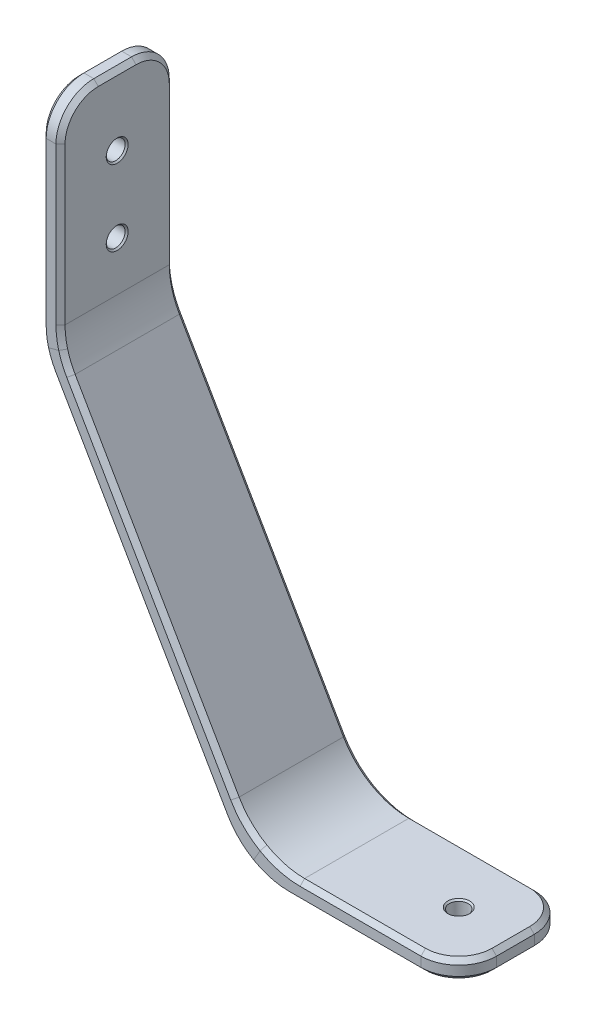
from build123d import *

# Parameters (mm, degrees)
SKETCH2_W                    = 3.175
SKETCH2_H                    = 19.05
F_1_8_0_125_DIAMETER_HOLE1_D = 3.175
F_1_8_0_125_DIAMETER_HOLE2_D = 3.175
FILLET1_R                    = 12.7
FILLET2_R                    = 6.35
CHAMFER3_SIZE                = 0.762
CHAMFER2_SIZE                = 0.254


with BuildPart() as part:
    # Sweep1: sweep along a path in Sketch1
    with BuildLine(Plane.XY) as sweep1_path:
        Line((0, 0), (0, -36.5125))
        Line((0, -36.5125), (33.61082832, -94.728162334))
        Line((33.61082832, -94.728162334), (68.53582832, -94.728162334))
    # Sketch2 → Sweep1 (sweep)
    with BuildSketch(Plane(origin=(0, 0, 0), x_dir=(1, 0, 0), z_dir=(0, 1, 0))):
        Rectangle(SKETCH2_W, SKETCH2_H)
    sweep(path=sweep1_path.line, transition=Transition.RIGHT)

    # 1/8 (0.125) Diameter Hole1 (through all)
    with Locations(Plane(origin=(1.5875, 0, 0), x_dir=(0, 0, -1), z_dir=(1, 0, 0))):
        with Locations((0, -11.693565329), (0, -24.393565329)):
            Hole(F_1_8_0_125_DIAMETER_HOLE1_D / 2)

    # 1/8 (0.125) Diameter Hole2 (through all)
    with Locations(Plane(origin=(0, -93.140662334, 0), x_dir=(1, 0, 0), z_dir=(0, 1, 0))):
        with Locations((59.01082832, 0)):
            Hole(F_1_8_0_125_DIAMETER_HOLE2_D / 2)

    # Fillet1
    fillet1_edges = [part.edges().sort_by_distance(p)[0] for p in [
        (1.5875, -36.087130657, 0),
        (-1.5875, -36.937869343, 0),
        (32.694284767, -96.315662334, 0),
        (34.527371872, -93.140662334, 0),
    ]]
    fillet(fillet1_edges, radius=FILLET1_R)

    # Fillet2
    fillet2_edges = [part.edges().sort_by_distance(p)[0] for p in [
        (0, 0, -9.525),
        (0, 0, 9.525),
        (68.53582832, -94.728162334, -9.525),
        (68.53582832, -94.728162334, 9.525),
    ]]
    fillet(fillet2_edges, radius=FILLET2_R)

    # Chamfer3
    chamfer3_edges = [part.edges().sort_by_distance(p)[0] for p in [
        (68.53582832, -96.315662334, 0),
        (66.67595638, -96.315662334, 7.665128061),
        (66.67595638, -96.315662334, -7.665128061),
        (68.53582832, -93.140662334, 0),
        (66.67595638, -93.140662334, 7.665128061),
        (66.67595638, -93.140662334, -7.665128061),
        (1.5875, 0, 0),
        (-1.5875, 0, 0),
        (-1.5875, -19.9424573, -9.525),
        (-1.5875, -19.9424573, 9.525),
        (-1.5875, -1.859871939, 7.665128061),
        (-1.5875, -1.859871939, -7.665128061),
        (1.5875, -19.517087957, -9.525),
        (1.5875, -19.517087957, 9.525),
        (1.5875, -1.859871939, 7.665128061),
        (1.5875, -1.859871939, -7.665128061),
        (51.106230753, -96.315662334, -9.525),
        (51.106230753, -96.315662334, 9.525),
        (52.022774305, -93.140662334, -9.525),
        (33.676633186, -94.614184962, -9.525),
        (14.571043965, -64.925288467, -9.525),
        (17.075087517, -62.912419124, -9.525),
        (-1.154757994, -36.821916472, -9.525),
        (33.676633186, -94.614184962, -9.525),
        (14.571043965, -64.925288467, 9.525),
        (17.075087517, -62.912419124, 9.525),
        (-1.154757994, -36.821916472, 9.525),
        (33.676633186, -94.614184962, 9.525),
        (52.022774305, -93.140662334, 9.525),
        (33.676633186, -94.614184962, 9.525),
        (-1.154757994, -36.821916472, -9.525),
        (-1.154757994, -36.821916472, 9.525),
        (35.509720291, -91.439184962, 9.525),
        (35.509720291, -91.439184962, 9.525),
        (35.509720291, -91.439184962, -9.525),
        (35.509720291, -91.439184962, -9.525),
        (2.020242006, -35.971177786, 9.525),
        (2.020242006, -35.971177786, 9.525),
        (2.020242006, -35.971177786, -9.525),
        (2.020242006, -35.971177786, -9.525),
    ]]
    chamfer(chamfer3_edges, length=CHAMFER3_SIZE)

    # Chamfer2
    chamfer2_edges = [part.edges().sort_by_distance(p)[0] for p in [
        (1.5875, -24.393565329, -1.5875),
        (-1.5875, -24.393565329, -1.5875),
        (1.5875, -11.693565329, -1.5875),
        (-1.5875, -11.693565329, -1.5875),
        (60.59832832, -93.140662334, 0),
        (60.59832832, -96.315662334, 0),
    ]]
    chamfer(chamfer2_edges, length=CHAMFER2_SIZE)


solid = part.part
